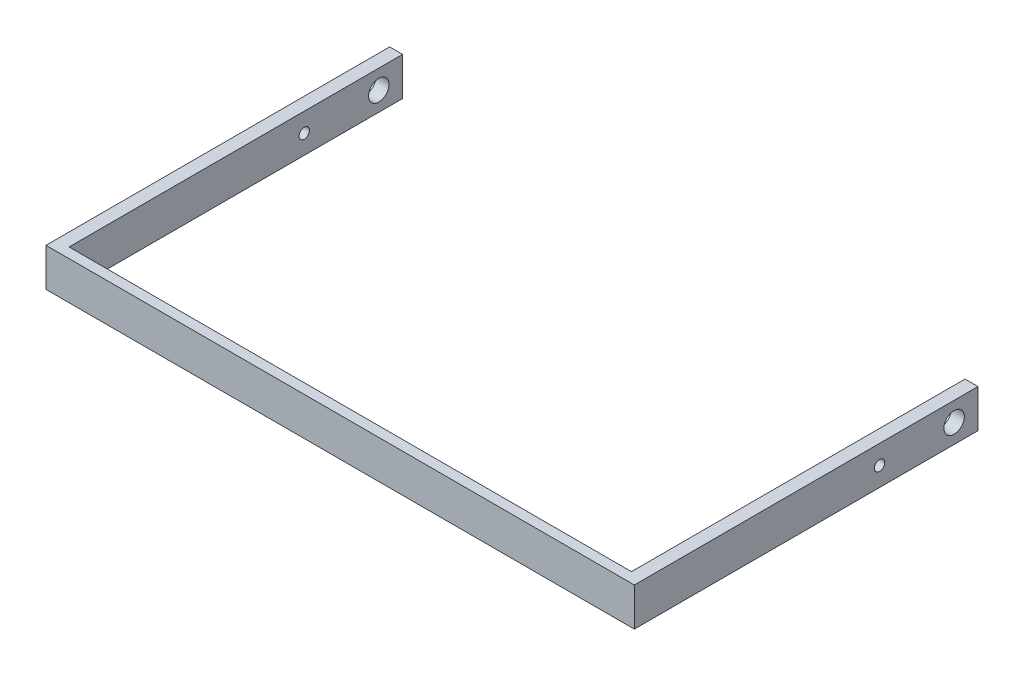
from build123d import *

# Parameters (mm, degrees)
SKETCH1_W           = 176.143624501
SKETCH1_H           = 20.199458611
SKETCH1_R           = 5.3975
SKETCH1_R_2         = 2.73924182
BOSS_EXTRUDE1_DEPTH = 6.858
SKETCH5_W           = 310.671331162
SKETCH5_H           = 20.199458611
BOSS_EXTRUDE4_DEPTH = 5.334


with BuildPart() as part:
    # Sketch1 → Boss-Extrude1 (new body)
    with BuildSketch(Plane.ZY):
        with Locations((220.759467441, -42.412189395)):
            Rectangle(SKETCH1_W, SKETCH1_H)
        with Locations((145.296375125, -42.412189394)):
            Circle(SKETCH1_R, mode=Mode.SUBTRACT)
        with Locations((184.665923862, -42.412189394)):
            Circle(SKETCH1_R_2, mode=Mode.SUBTRACT)
    boss_extrude1 = extrude(amount=BOSS_EXTRUDE1_DEPTH)

    # Sketch5 → Boss-Extrude4 (add)
    with BuildSketch(Plane.XY.offset(308.831279691)):
        with Locations((148.477665581, -42.412189395)):
            Rectangle(SKETCH5_W, SKETCH5_H)
    extrude(amount=BOSS_EXTRUDE4_DEPTH)

    # Mirror1: Boss-Extrude1 across plane
    add(boss_extrude1.mirror(Plane.ZY.offset(-148.477665581)))


solid = part.part
